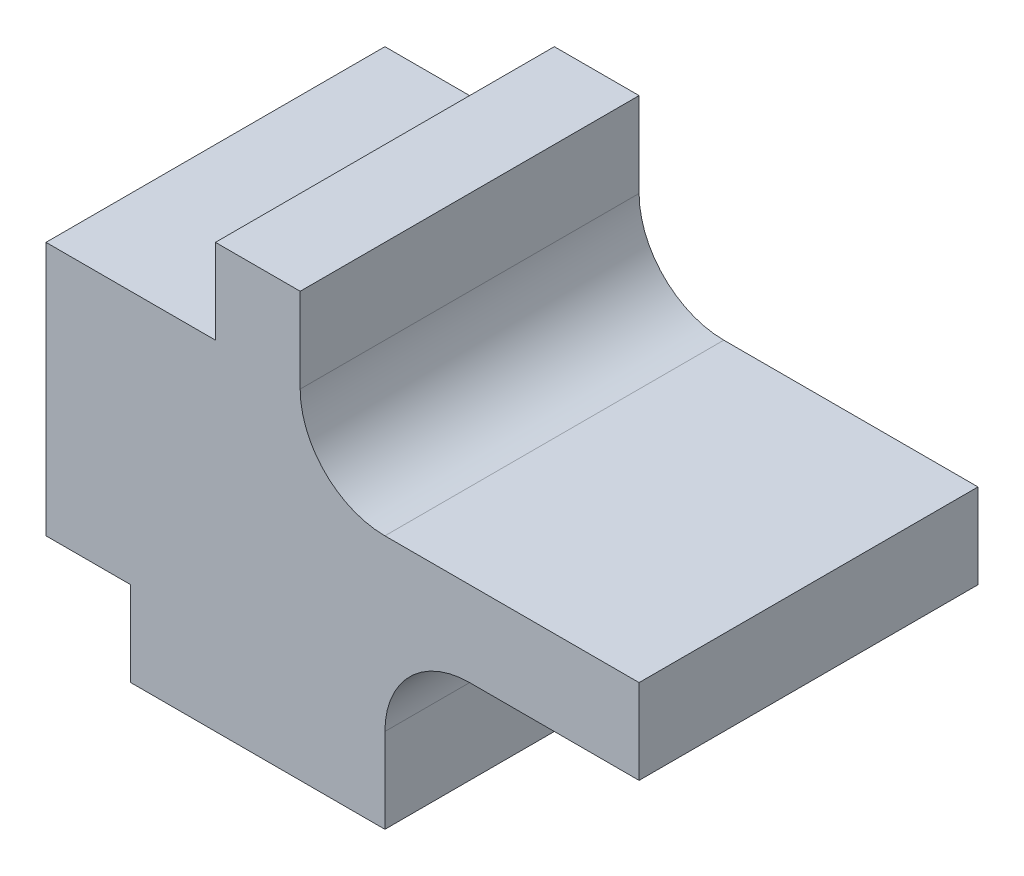
from build123d import *

# Parameters (mm, degrees)
EXTRUDE_1_DEPTH = 4


with BuildPart() as part:
    # 草圖1 → 填料-伸長1 (new body)
    with BuildSketch(Plane.XY):
        with BuildLine():
            Line((0, 0), (3, 0))
            Line((3, 0), (3, 1))
            ThreePointArc((3, 1), (3.292893219, 1.707106781), (4, 2))
            Line((4, 2), (6, 2))
            Line((6, 2), (6, 3))
            Line((6, 3), (3, 3))
            ThreePointArc((3, 3), (2.292893219, 3.292893219), (2, 4))
            Line((2, 4), (2, 5))
            Line((2, 5), (1, 5))
            Line((1, 5), (1, 4))
            Line((1, 4), (-1, 4))
            Line((-1, 4), (-1, 1))
            Line((-1, 1), (0, 1))
            Line((0, 1), (0, 0))
        make_face()
    extrude(amount=EXTRUDE_1_DEPTH)


solid = part.part
